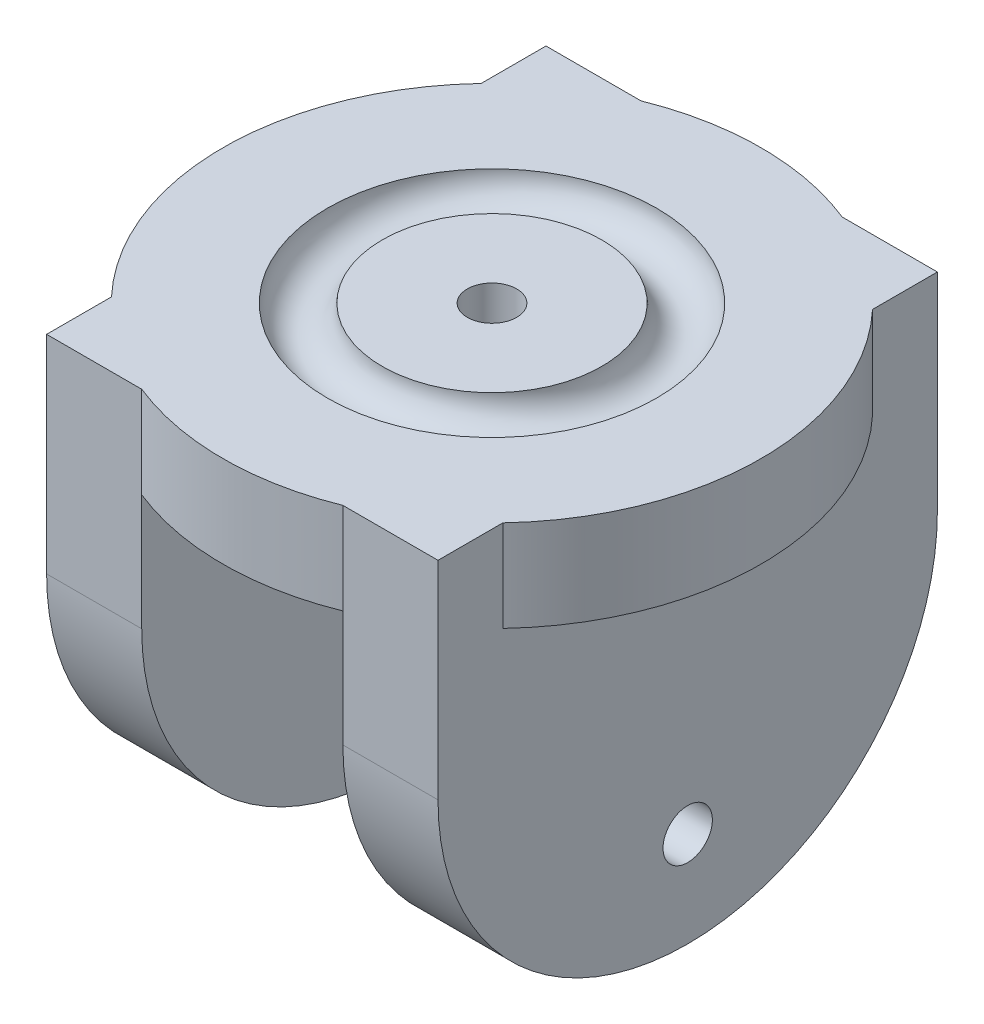
from build123d import *

# Parameters (mm, degrees)
SKETCH1_R                = 29.440979716
BOSS_EXTRUDE1_DEPTH      = 10
SKETCH2_W                = 10.403384244
SKETCH2_H                = 54.617626702
BOSS_EXTRUDE2_DEPTH      = 40
BOSS_EXTRUDE2_DEPTH_BACK = 10
SKETCH3_R                = 2.7
CUT_EXTRUDE1_DEPTH       = 80
SKETCH4_R                = 2.7
CUT_EXTRUDE2_DEPTH       = 80
CUT_EXTRUDE2_DEPTH_BACK  = 80
SKETCH6_R                = 3
CUT_EXTRUDE3_DEPTH       = 80


with BuildPart() as part:
    # Sketch1 → Boss-Extrude1 (new body)
    with BuildSketch(Plane(origin=(0, 0, 0), x_dir=(1, 0, 0), z_dir=(0, 1, 0))):
        Circle(SKETCH1_R)
    extrude(amount=BOSS_EXTRUDE1_DEPTH)

    # Sketch2 → Boss-Extrude2 (add, two sides)
    with BuildSketch(Plane.XZ) as boss_extrude2_sk:
        with Locations((-16.201692122, 0)):
            Rectangle(SKETCH2_W, SKETCH2_H)
        with Locations((16.201692122, 0)):
            Rectangle(SKETCH2_W, SKETCH2_H)
    extrude(amount=BOSS_EXTRUDE2_DEPTH)
    extrude(boss_extrude2_sk.sketch, amount=-BOSS_EXTRUDE2_DEPTH_BACK)

    # Sketch3 → Cut-Extrude1 (cut)
    with BuildSketch(Plane(origin=(21.403384244, 0, 0), x_dir=(0, 0, -1), z_dir=(1, 0, 0))):
        with Locations((0, -29.584442491)):
            Circle(SKETCH3_R)
    extrude(amount=-CUT_EXTRUDE1_DEPTH, mode=Mode.SUBTRACT)

    # Sketch4 → Cut-Extrude2 (cut, two sides)
    with BuildSketch(Plane(origin=(0, 10, 0), x_dir=(1, 0, 0), z_dir=(0, 1, 0))) as cut_extrude2_sk:
        Circle(SKETCH4_R)
    extrude(amount=CUT_EXTRUDE2_DEPTH, mode=Mode.SUBTRACT)
    extrude(cut_extrude2_sk.sketch, amount=-CUT_EXTRUDE2_DEPTH_BACK, mode=Mode.SUBTRACT)

    # Cut-Sweep1: sweep along a path in Sketch5
    with BuildLine(Plane(origin=(0, 10, 0), x_dir=(1, 0, 0), z_dir=(0, 1, 0))) as cut_sweep1_path:
        CenterArc((0, 0), 15, 0, 360)
    # Sketch6 → Cut-Sweep1 (sweep, cut)
    with BuildSketch(Plane.XY):
        with Locations((-15, 10)):
            Circle(SKETCH6_R)
    sweep(path=cut_sweep1_path.line, mode=Mode.SUBTRACT)

    # Sketch8 → Cut-Extrude3 (cut)
    with BuildSketch(Plane.ZY.offset(21.403384244)):
        with BuildLine():
            Line((-27.308813351, -12.691186649), (-33.56023991, -12.691186649))
            Line((-33.56023991, -12.691186649), (-33.56023991, -51.85966326))
            Line((-33.56023991, -51.85966326), (31.545819747, -51.85966326))
            Line((31.545819747, -51.85966326), (31.545819747, -12.691186649))
            Line((31.545819747, -12.691186649), (27.308813351, -12.691186649))
            ThreePointArc((27.308813351, -12.691186649), (0, -40), (-27.308813351, -12.691186649))
        make_face()
    extrude(amount=-CUT_EXTRUDE3_DEPTH, mode=Mode.SUBTRACT)


solid = part.part
